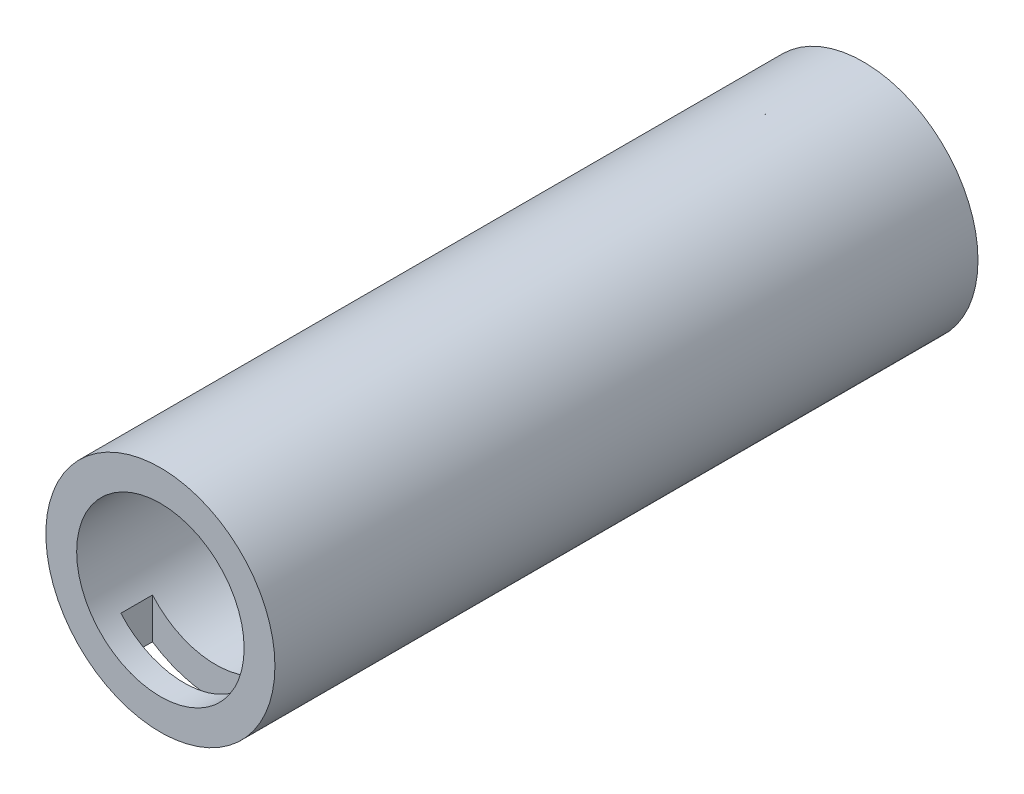
from build123d import *

# Parameters (mm, degrees)
SKETCH1_R               = 18.415
BOSS_EXTRUDE2_DEPTH     = 113.03
SKETCH4_W               = 20.32
SKETCH4_H               = 5.08
CUT_EXTRUDE2_DEPTH      = 12.7
CUT_EXTRUDE2_DEPTH_BACK = 22.86
CUT_EXTRUDE3_START      = -5.08
SKETCH5_R               = 13.462
CUT_EXTRUDE3_DEPTH      = 107.95


with BuildPart() as part:
    # Sketch1 → Boss-Extrude2 (new body)
    with BuildSketch(Plane.XY):
        Circle(SKETCH1_R)
    extrude(amount=BOSS_EXTRUDE2_DEPTH)

    # Sketch4 → Cut-Extrude2 (cut, two sides)
    with BuildSketch(Plane(origin=(0, 0, 0), x_dir=(1, 0, 0), z_dir=(0, 1, 0))) as cut_extrude2_sk:
        with Locations((0, -106.68)):
            Rectangle(SKETCH4_W, SKETCH4_H)
    extrude(amount=CUT_EXTRUDE2_DEPTH, mode=Mode.SUBTRACT)
    extrude(cut_extrude2_sk.sketch, amount=-CUT_EXTRUDE2_DEPTH_BACK, mode=Mode.SUBTRACT)

    # Sketch5 → Cut-Extrude3 (cut)
    with BuildSketch(Plane(origin=(0, 0, 0), x_dir=(-1, 0, 0), z_dir=(0, 0, -1)).offset(CUT_EXTRUDE3_START)):
        Circle(SKETCH5_R)
    extrude(amount=-CUT_EXTRUDE3_DEPTH, mode=Mode.SUBTRACT)


solid = part.part
